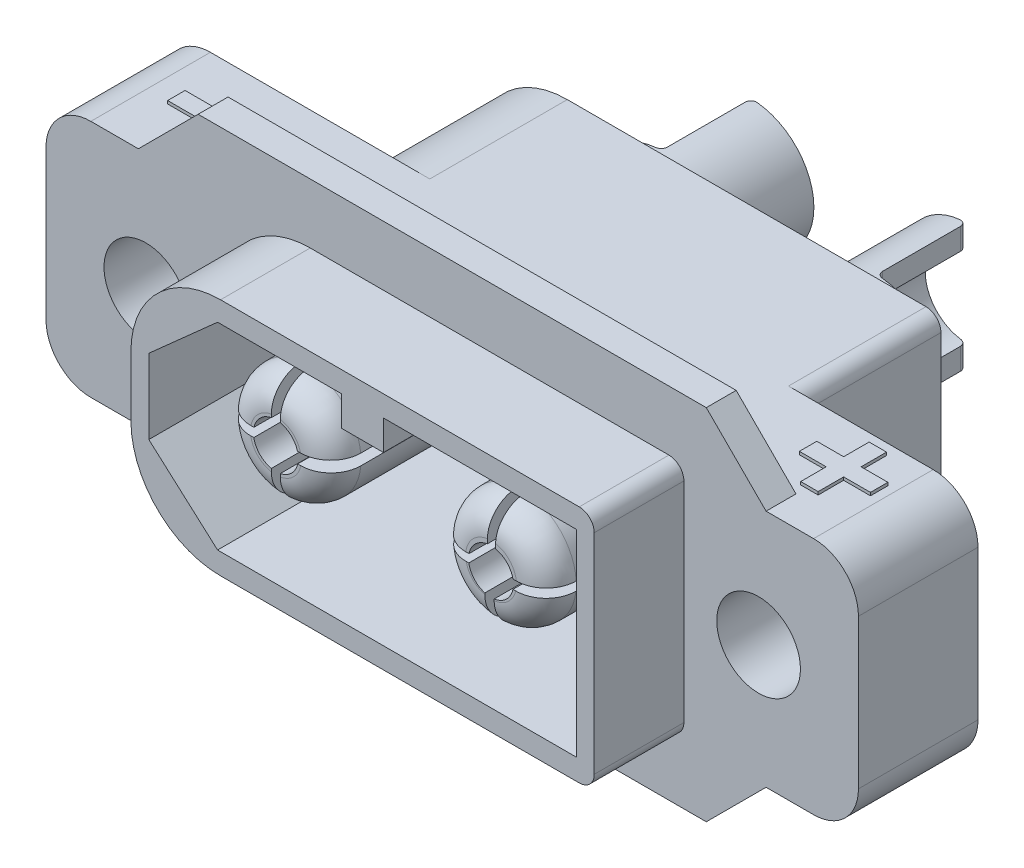
from build123d import *

# Parameters (mm, degrees)
SKETCH1_W                 = 15.5
SKETCH1_H                 = 8
BOSS_EXTRUDE1_DEPTH       = 3
BOSS_EXTRUDE1_DEPTH_BACK  = 8.6
FILLET1_R                 = 3
FILLET2_R                 = 0.5
SKETCH2_W                 = 27.18
SKETCH2_H                 = 8
BOSS_EXTRUDE2_DEPTH       = 4
FILLET3_R                 = 1.5
CUT_EXTRUDE1_DEPTH        = 1
BOSS_EXTRUDE3_DEPTH       = 1
SKETCH5_R                 = 1.4
CUT_EXTRUDE2_DEPTH        = 9.6
CUT_EXTRUDE3_DEPTH        = 2
CUT_EXTRUDE4_DEPTH        = 8.8
SKETCH8_R                 = 2.1
BOSS_EXTRUDE4_DEPTH       = 6
F_2_5MM_DOWEL_HOLE1_D     = 2.75
F_2_5MM_DOWEL_HOLE1_DEPTH = 6
F_2_5MM_DOWEL_HOLE1_TIP   = 0.826183351
SKETCH11_W                = 3.440433193
SKETCH11_H                = 4.792031948
SKETCH11_W_2              = 3.391284148
SKETCH11_H_2              = 4.542096385
CUT_EXTRUDE5_DEPTH        = 4.4
FILLET4_R                 = 0.2
SKETCH12_R                = 1.85
BOSS_EXTRUDE5_DEPTH       = 8.1
FILLET5_R                 = 1
CUT_EXTRUDE6_DEPTH        = 8.1
SKETCH15_W                = 1.211538462
SKETCH15_H                = 0.583333334
BOSS_EXTRUDE6_DEPTH       = 0.1


with BuildPart() as part:
    # Sketch1 → Boss-Extrude1 (new body, two sides)
    with BuildSketch(Plane.XY) as boss_extrude1_sk:
        Rectangle(SKETCH1_W, SKETCH1_H)
    extrude(amount=BOSS_EXTRUDE1_DEPTH)
    extrude(boss_extrude1_sk.sketch, amount=-BOSS_EXTRUDE1_DEPTH_BACK)

    # Fillet1
    fillet1_edges = [part.edges().sort_by_distance(p)[0] for p in [
        (-7.75, 4, -2.8),
        (-7.75, -4, -2.8),
    ]]
    fillet(fillet1_edges, radius=FILLET1_R)

    # Fillet2
    fillet2_edges = [part.edges().sort_by_distance(p)[0] for p in [
        (7.75, 4, -2.8),
        (7.75, -4, -2.8),
    ]]
    fillet(fillet2_edges, radius=FILLET2_R)

    # Sketch2 → Boss-Extrude2 (add)
    with BuildSketch(Plane.XY):
        Rectangle(SKETCH2_W, SKETCH2_H)
    extrude(amount=-BOSS_EXTRUDE2_DEPTH)

    # Fillet3
    fillet3_edges = [part.edges().sort_by_distance(p)[0] for p in [
        (13.59, -4, -2),
        (-13.59, 4, -2),
        (-13.59, -4, -2),
        (13.59, 4, -2),
    ]]
    fillet(fillet3_edges, radius=FILLET3_R)

    # Sketch3 → Cut-Extrude1 (cut)
    with BuildSketch(Plane(origin=(0, 0, -8.6), x_dir=(-1, 0, 0), z_dir=(0, 0, -1))):
        with BuildLine():
            Line((-7.05, 3.3), (-7.05, -3.3))
            Line((-7.05, -3.3), (4.75, -3.3))
            ThreePointArc((4.75, -3.3), (6.376345597, -2.626345597), (7.05, -1))
            Line((7.05, -1), (7.05, 1))
            ThreePointArc((7.05, 1), (6.376345597, 2.626345597), (4.75, 3.3))
            Line((4.75, 3.3), (-7.05, 3.3))
        make_face()
    extrude(amount=-CUT_EXTRUDE1_DEPTH, mode=Mode.SUBTRACT)

    # Sketch4 → Boss-Extrude3 (add)
    with BuildSketch(Plane.XY):
        Polygon((8.5, 6), (10.5, 4), (10.5, -4), (8.5, -6), (-8.5, -6), (-10.5, -4), (-10.5, 4), (-8.5, 6), align=None)
    extrude(amount=-BOSS_EXTRUDE3_DEPTH)

    # Sketch5 → Cut-Extrude2 (cut, through all)
    with BuildSketch(Plane.XY):
        with Locations((10.25, 0)):
            Circle(SKETCH5_R)
        with Locations((-10.25, 0)):
            Circle(SKETCH5_R)
    extrude(amount=-CUT_EXTRUDE2_DEPTH, mode=Mode.SUBTRACT)

    # Sketch6 → Cut-Extrude3 (cut)
    with BuildSketch(Plane(origin=(0, 0, -4), x_dir=(-1, 0, 0), z_dir=(0, 0, -1))):
        Polygon((-10.25, 2.817469314), (-12.69, 1.408734657), (-12.69, -1.408734657), (-10.25, -2.817469314), (-7.81, -1.408734657), (-7.81, 1.408734657), align=None)
        Polygon((10.25, 2.817469314), (7.81, 1.408734657), (7.81, -1.408734657), (10.25, -2.817469314), (12.69, -1.408734657), (12.69, 1.408734657), align=None)
    extrude(amount=-CUT_EXTRUDE3_DEPTH, mode=Mode.SUBTRACT)

    # Sketch7 → Cut-Extrude4 (cut)
    with BuildSketch(Plane.XY.offset(3)):
        Polygon((7.15, 3.3), (7.15, -3.3), (-4.85, -3.3), (-7.15, -1.25), (-7.15, 1.25), (-4.85, 3.3), (-0.7, 3.3), (-0.7, 2.3), (0.7, 2.3), (0.7, 3.3), align=None)
    extrude(amount=-CUT_EXTRUDE4_DEPTH, mode=Mode.SUBTRACT)

    # Sketch8 → Boss-Extrude4 (add)
    with BuildSketch(Plane(origin=(0, 0, -7.6), x_dir=(-1, 0, 0), z_dir=(0, 0, -1))):
        with Locations((-3.6, 0)):
            Circle(SKETCH8_R)
        with Locations((3.6, 0)):
            Circle(SKETCH8_R)
    extrude(amount=BOSS_EXTRUDE4_DEPTH)

    # Ø2.5mm Dowel Hole1
    with Locations(Plane(origin=(0, 0, -13.6), x_dir=(-1, 0, 0), z_dir=(0, 0, -1))):
        with Locations((-3.6, 0), (3.6, 0)):
            Hole(F_2_5MM_DOWEL_HOLE1_D / 2, depth=F_2_5MM_DOWEL_HOLE1_DEPTH)
            with Locations((0, 0, -(F_2_5MM_DOWEL_HOLE1_DEPTH + F_2_5MM_DOWEL_HOLE1_TIP / 2))):  # 118° drill point
                Cone(0, F_2_5MM_DOWEL_HOLE1_D / 2, F_2_5MM_DOWEL_HOLE1_TIP, mode=Mode.SUBTRACT)

    # Sketch11 → Cut-Extrude5 (cut, symmetric)
    with BuildSketch(Plane(origin=(0, 0, 0), x_dir=(1, 0, 0), z_dir=(0, 1, 0))):
        with Locations((-5.320216596, 12.996015974)):
            Rectangle(SKETCH11_W, SKETCH11_H)
        with Locations((5.295642074, 12.871048193)):
            Rectangle(SKETCH11_W_2, SKETCH11_H_2)
    extrude(amount=CUT_EXTRUDE5_DEPTH, both=True, mode=Mode.SUBTRACT)

    # Fillet4
    fillet4_edges = [part.edges().sort_by_distance(p)[0] for p in [
        (-3.6, 1.7375, -10.6),
        (-3.6, -1.7375, -10.6),
        (-3.6, 1.7375, -13.6),
        (-3.6, -1.7375, -13.6),
        (3.6, 1.7375, -10.6),
        (3.6, -1.7375, -10.6),
        (3.6, -1.7375, -13.6),
        (3.6, 1.7375, -13.6),
    ]]
    fillet(fillet4_edges, radius=FILLET4_R)

    # Sketch12 → Boss-Extrude5 (add)
    with BuildSketch(Plane.XY.offset(-5.8)):
        with Locations((-3.6, 0)):
            Circle(SKETCH12_R)
        with Locations((3.6, 0)):
            Circle(SKETCH12_R)
    extrude(amount=BOSS_EXTRUDE5_DEPTH)

    # Fillet5
    fillet5_edges = [part.edges().sort_by_distance(p)[0] for p in [
        (-5.45, 0, 2.3),
        (1.75, 0, 2.3),
    ]]
    fillet(fillet5_edges, radius=FILLET5_R)

    # Sketch14 → Cut-Extrude6 (cut)
    with BuildSketch(Plane.XY.offset(2.3)):
        with BuildLine():
            Line((-3.75, 0.734846923), (-3.75, 2.518888588))
            Line((-3.75, 2.518888588), (-3.45, 2.518888588))
            Line((-3.45, 2.518888588), (-3.45, 0.734846923))
            ThreePointArc((-3.45, 0.734846923), (-3.088291525, 0.548319648), (-2.877253172, 0.200342265))
            Line((-2.877253172, 0.200342265), (-0.812059785, 0.200342265))
            Line((-0.812059785, 0.200342265), (-0.812059785, -0.16487495))
            Line((-0.812059785, -0.16487495), (-2.868346905, -0.16487495))
            ThreePointArc((-2.868346905, -0.16487495), (-3.075076142, -0.535681755), (-3.45, -0.734846923))
            Line((-3.45, -0.734846923), (-3.45, -2.518888588))
            Line((-3.45, -2.518888588), (-3.75, -2.518888588))
            Line((-3.75, -2.518888588), (-3.75, -0.734846923))
            ThreePointArc((-3.75, -0.734846923), (-4.135554442, -0.52505375), (-4.337672773, -0.135421123))
            Line((-4.337672773, -0.135421123), (-5.890094849, -0.16456694))
            Line((-5.890094849, -0.16456694), (-5.890094849, 0.13543306))
            Line((-5.890094849, 0.13543306), (-4.331732975, 0.164520069))
            ThreePointArc((-4.331732975, 0.164520069), (-4.12505375, 0.535554442), (-3.75, 0.734846923))
        make_face()
        with BuildLine():
            Line((3.392079477, -2.61864316), (3.703960261, -2.61864316))
            Line((3.703960261, -2.61864316), (3.703960261, -0.792072113))
            ThreePointArc((3.703960261, -0.792072113), (4.111188681, -0.594965873), (4.33096163, -0.199509546))
            Line((4.33096163, -0.199509546), (6.020422905, -0.199509546))
            Line((6.020422905, -0.199509546), (6.020422905, 0.1))
            Line((6.020422905, 0.1), (4.3309117, 0.1))
            ThreePointArc((4.3309117, 0.1), (4.126414102, 0.480408518), (3.746039739, 0.684969637))
            Line((3.746039739, 0.684969637), (3.8, 2.518888588))
            Line((3.8, 2.518888588), (3.5, 2.518888588))
            Line((3.5, 2.518888588), (3.475216106, 0.690326503))
            ThreePointArc((3.475216106, 0.690326503), (3.076256051, 0.490793517), (2.861167778, 0.1))
            Line((2.861167778, 0.1), (1.179577095, 0.1))
            Line((1.179577095, 0.1), (1.179577095, -0.2))
            Line((1.179577095, -0.2), (2.855835949, -0.170700918))
            ThreePointArc((2.855835949, -0.170700918), (3.036455243, -0.549242075), (3.392079477, -0.771611456))
            Line((3.392079477, -0.771611456), (3.392079477, -2.61864316))
        make_face()
    extrude(amount=-CUT_EXTRUDE6_DEPTH, mode=Mode.SUBTRACT)

    # Sketch15 → Boss-Extrude6 (add)
    with BuildSketch(Plane(origin=(0, 4, 0), x_dir=(1, 0, 0), z_dir=(0, 1, 0))):
        with Locations((-10.701923077, 2.078846154)):
            Rectangle(SKETCH15_W, SKETCH15_H)
        Polygon((10.320512821, 2.774358974), (10.320512821, 3.626923077), (10.903846154, 3.626923077), (10.903846154, 2.774358974), (11.801282051, 2.774358974), (11.801282051, 2.191025641), (10.903846154, 2.191025641), (10.903846154, 1.338461538), (10.320512821, 1.338461538), (10.320512821, 2.191025641), (9.423076923, 2.191025641), (9.423076923, 2.774358974), align=None)
    extrude(amount=BOSS_EXTRUDE6_DEPTH)


solid = part.part
